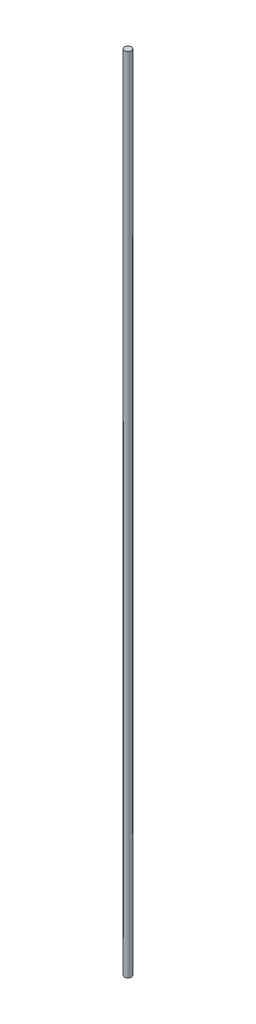
from build123d import *

# Parameters (mm, degrees)
SKETCH1_R           = 25.5
BOSS_EXTRUDE1_DEPTH = 6000


with BuildPart() as part:
    # Sketch1 → Boss-Extrude1 (new body)
    with BuildSketch(Plane(origin=(0, 0, 0), x_dir=(1, 0, 0), z_dir=(0, 1, 0))):
        Circle(SKETCH1_R)
    extrude(amount=BOSS_EXTRUDE1_DEPTH)


solid = part.part
